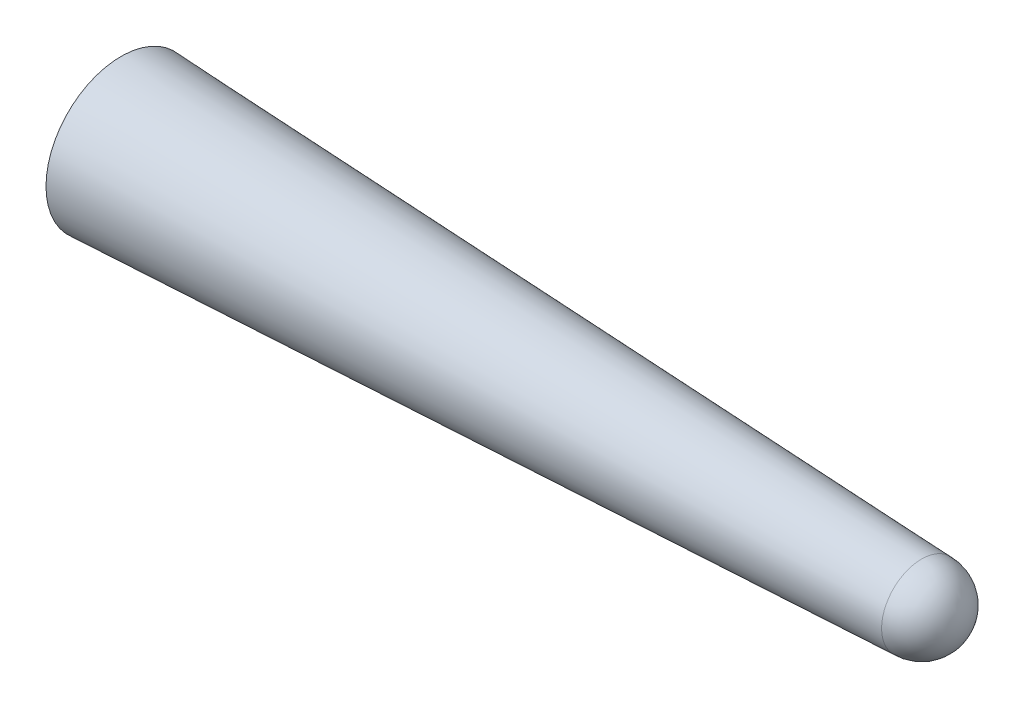
from build123d import *


with BuildPart() as part:
    # Sketch1 → Revolve1 (revolve)
    with BuildSketch(Plane.XY):
        with BuildLine():
            Line((-105.609644073, -24.191844409), (-105.609644073, -16.691844409))
            Line((-105.609644073, -16.691844409), (-25.609644073, -20.191844409))
            ThreePointArc((-25.609644073, -20.191844409), (-22.781216948, -21.363417284), (-21.609644073, -24.191844409))
            Line((-21.609644073, -24.191844409), (-105.609644073, -24.191844409))
        make_face()
    revolve(axis=Axis((-105.609644073, -24.191844409, 0), (1, 0, 0)))


solid = part.part
